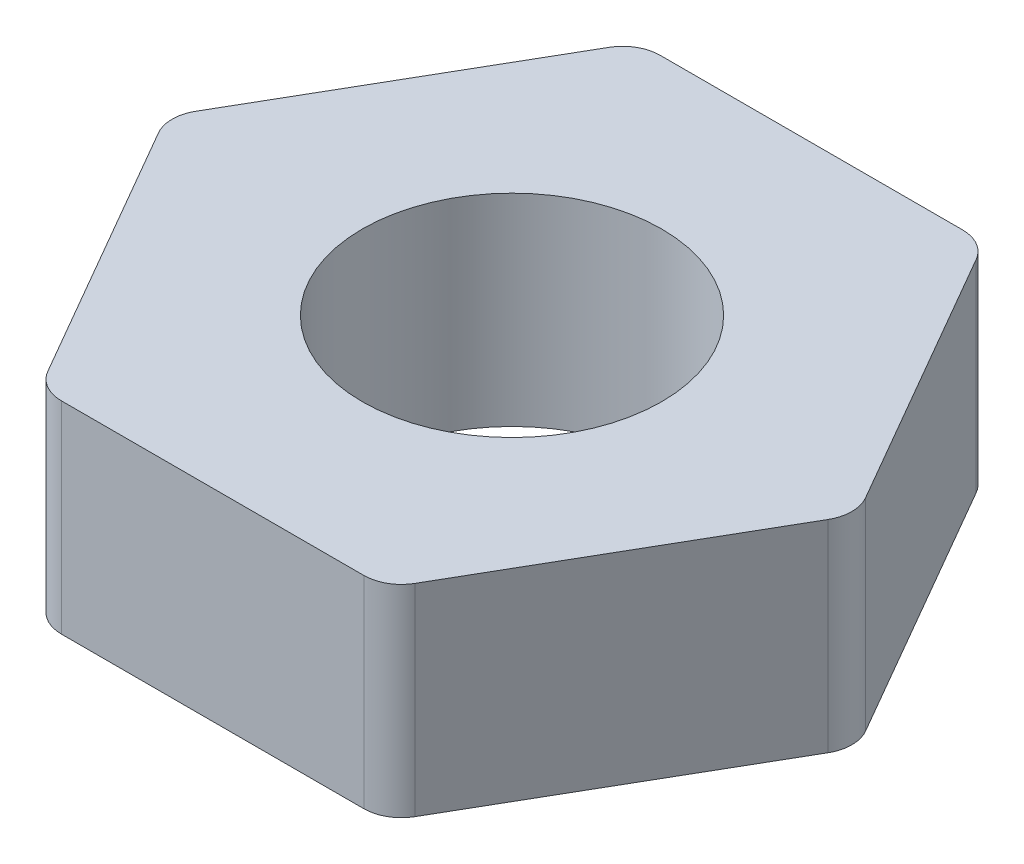
from build123d import *

# Parameters (mm, degrees)
SKETCH_1_R      = 2
EXTRUDE_1_DEPTH = 2.7
FILLET_1_R      = 0.5


with BuildPart() as part:
    # Эскиз1 → Бобышка-Вытянуть1 (new body)
    with BuildSketch(Plane(origin=(0, 0, 0), x_dir=(1, 0, 0), z_dir=(0, 1, 0))):
        Polygon((4.618802154, 0), (2.309401077, 4), (-2.309401077, 4), (-4.618802154, 0), (-2.309401077, -4), (2.309401077, -4), align=None)
        Circle(SKETCH_1_R, mode=Mode.SUBTRACT)
    extrude(amount=EXTRUDE_1_DEPTH)

    # Скругление1
    fillet_1_edges = [part.edges().sort_by_distance(p)[0] for p in [
        (-4.618802154, 1.35, 0),
        (-2.309401077, 1.35, 4),
        (2.309401077, 1.35, 4),
        (4.618802154, 1.35, 0),
        (-2.309401077, 1.35, -4),
        (2.309401077, 1.35, -4),
    ]]
    fillet(fillet_1_edges, radius=FILLET_1_R)


solid = part.part
